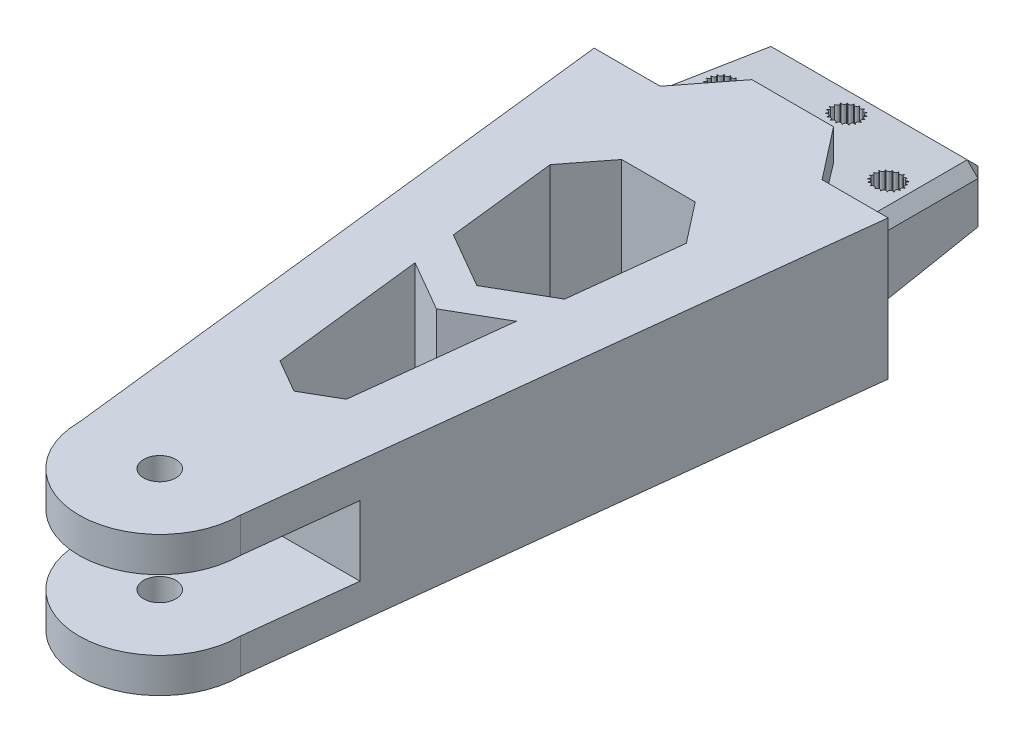
from build123d import *
from OCP.BRepFilletAPI import BRepFilletAPI_MakeChamfer

# Parameters (mm, degrees)
SKETCH2_R           = 3
SKETCH2_R_2         = 5
BOSS_EXTRUDE1_DEPTH = 26
SKETCH3_W           = 70
SKETCH3_H           = 13
CUT_EXTRUDE1_DEPTH  = 27.5
CUT_EXTRUDE2_DEPTH  = 63
CUT_EXTRUDE3_DEPTH  = 101
BOSS_EXTRUDE2_START = -9.6
SKETCH8_W           = 44.742467558
SKETCH8_H           = 16
BOSS_EXTRUDE2_DEPTH = 26
BOSS_EXTRUDE2_TAPER = 5
CUT_EXTRUDE4_REACH  = 145.455
SKETCH10_R          = 2
CHAMFER1_SIZE       = 2
CHAMFER1_SIZE2      = 2.200125735
CHAMFER1_SIZE2_2    = 2.015367123
CUT_EXTRUDE6_DEPTH  = 54
BOSS_EXTRUDE3_DEPTH = 26
SKETCH13_R          = 2
CUT_EXTRUDE7_DEPTH  = 22


with BuildPart() as part:
    # Sketch2 → Boss-Extrude1 (new body)
    with BuildSketch(Plane(origin=(0, 0, 0), x_dir=(1, 0, 0), z_dir=(0, 1, 0))):
        with BuildLine():
            ThreePointArc((15, 350), (0, 365), (-15, 350))
            Line((-15, 350), (-31.325519493, 207.151704434))
            Line((-31.325519493, 207.151704434), (-24.254451681, 200.080636622))
            Line((-24.254451681, 200.080636622), (-24.254451681, 149.919363378))
            Line((-24.254451681, 149.919363378), (-31.325519493, 142.848295566))
            Line((-31.325519493, 142.848295566), (-15, 0))
            ThreePointArc((-15, 0), (0, -15), (15, 0))
            Line((15, 0), (31.325519493, 142.848295566))
            Line((31.325519493, 142.848295566), (24.254451681, 149.919363378))
            Line((24.254451681, 149.919363378), (24.254451681, 200.080636622))
            Line((24.254451681, 200.080636622), (31.325519493, 207.151704434))
            Line((31.325519493, 207.151704434), (15, 350))
        make_face()
        with Locations(Location((0, 0, 0), (0, 0, 90))):
            Circle(SKETCH2_R, mode=Mode.SUBTRACT)
        with Locations(Location((0, 175, 0), (0, 0, 90))):
            Circle(SKETCH2_R_2, mode=Mode.SUBTRACT)
        with Locations(Location((0, 350, 0), (0, 0, 90))):
            Circle(SKETCH2_R, mode=Mode.SUBTRACT)
    extrude(amount=BOSS_EXTRUDE1_DEPTH)

    # Sketch3 → Cut-Extrude1 (cut, symmetric)
    with BuildSketch(Plane(origin=(0, 0, 0), x_dir=(0, 0, -1), z_dir=(1, 0, 0))):
        with Locations((-15, 13)):
            Rectangle(SKETCH3_W, SKETCH3_H)
    cut_extrude1 = extrude(amount=CUT_EXTRUDE1_DEPTH, both=True, mode=Mode.SUBTRACT)

    # Sketch5 → Cut-Extrude2 (cut, symmetric)
    with BuildSketch(Plane(origin=(24.254451681, 0, 0), x_dir=(0, 0, -1), z_dir=(1, 0, 0))):
        Polygon((142.848295566, 26), (149.919363378, 23.456766037), (200.080636622, 23.456766037), (207.151704434, 26), align=None)
        Polygon((207.151704434, 0), (200.080636622, 2.543233963), (149.919363378, 2.543233963), (142.848295566, 0), align=None)
    extrude(amount=CUT_EXTRUDE2_DEPTH, both=True, mode=Mode.SUBTRACT)

    # Mirror3: Cut-Extrude1 across plane
    add(cut_extrude1.mirror(Plane.XY.offset(-175)), mode=Mode.SUBTRACT)

    # Sketch7 → Cut-Extrude3 (cut)
    with BuildSketch(Plane(origin=(0, 26, 0), x_dir=(1, 0, 0), z_dir=(0, 1, 0))):
        Polygon((7.6, 117.848295566), (-7.6, 117.848295566), (-15.071233779, 108.248295566), (-27.371233779, 108.248295566), (-64.491308862, 177.382723315), (-40.66046147, 301.084223493), (-15.371233779, 412.054906588), (101.659229405, 225.690460338), (42.092569242, 95.10562793), (27.371233779, 108.248295566), (15.071233779, 108.248295566), align=None)
    extrude(amount=-CUT_EXTRUDE3_DEPTH, mode=Mode.SUBTRACT)

    # Sketch8 → Boss-Extrude2 (add)
    with BuildSketch(Plane(origin=(0, 0, -117.848295566), x_dir=(-1, 0, 0), z_dir=(0, 0, -1)).offset(BOSS_EXTRUDE2_START)):
        with Locations((0, 13)):
            Rectangle(SKETCH8_W, SKETCH8_H)
    extrude(amount=BOSS_EXTRUDE2_DEPTH, taper=BOSS_EXTRUDE2_TAPER)

    # Cut-Extrude4: from a plane face, 145.455 long prism both ways, kept between that surface and its translate by the depth
    cut_extrude4_start = Plane(origin=(15.071233779, 21, -108.248295566), z_dir=(0, 0.9961946980917455, -0.08715574274765836)) * Box(583.82, 583.82, 291.91, align=(Align.CENTER, Align.CENTER, Align.MIN), mode=Mode.PRIVATE)
    cut_extrude4_end = Plane(origin=(15.071233779, 17, -108.248295566), z_dir=(0, 0.9961946980917455, -0.08715574274765836)) * Box(583.82, 583.82, 291.91, align=(Align.CENTER, Align.CENTER, Align.MIN), mode=Mode.PRIVATE)
    # Sketch10 → Cut-Extrude4 (cut, from a surface)
    with BuildSketch(Plane(origin=(0, 26, 0), x_dir=(1, 0, 0), z_dir=(0, 1, 0)), mode=Mode.PRIVATE) as cut_extrude4_sk1:
        with BuildLine():
            ThreePointArc((-0.17288727, 130.592855639), (-0.2270932, 130.588902922), (-0.281210428, 130.583879726))
            ThreePointArc((-0.281210428, 130.583879726), (-0.576890895, 130.126386191), (-1.054676959, 130.388011399))
            ThreePointArc((-1.054676959, 130.388011399), (-1.104662418, 130.366672214), (-1.154216396, 130.344349354))
            ThreePointArc((-1.154216396, 130.344349354), (-1.285328172, 129.81563679), (-1.822176035, 129.907949541))
            ThreePointArc((-1.822176035, 129.907949541), (-1.862524322, 129.87153632), (-1.902145108, 129.834332823))
            ThreePointArc((-1.902145108, 129.834332823), (-1.854480197, 129.291695441), (-2.392214064, 129.204692216))
            ThreePointArc((-2.392214064, 129.204692216), (-2.418552816, 129.157150897), (-2.443946883, 129.10909834))
            ThreePointArc((-2.443946883, 129.10909834), (-2.222670518, 128.611339319), (-2.70301858, 128.354448267))
            ThreePointArc((-2.70301858, 128.354448267), (-2.712493584, 128.300930689), (-2.720909091, 128.247236312))
            ThreePointArc((-2.720909091, 128.247236312), (-2.35, 127.848295566), (-2.720909091, 127.44935482))
            ThreePointArc((-2.720909091, 127.44935482), (-2.712493584, 127.395660443), (-2.70301858, 127.342142865))
            ThreePointArc((-2.70301858, 127.342142865), (-2.222670518, 127.085251813), (-2.443946883, 126.587492792))
            ThreePointArc((-2.443946883, 126.587492792), (-2.418552816, 126.539440235), (-2.392214064, 126.491898916))
            ThreePointArc((-2.392214064, 126.491898916), (-1.854480197, 126.404895691), (-1.902145108, 125.862258309))
            ThreePointArc((-1.902145108, 125.862258309), (-1.862524322, 125.825054812), (-1.822176035, 125.788641591))
            ThreePointArc((-1.822176035, 125.788641591), (-1.285328172, 125.880954342), (-1.154216396, 125.352241778))
            ThreePointArc((-1.154216396, 125.352241778), (-1.104662418, 125.329918918), (-1.054676959, 125.308579733))
            ThreePointArc((-1.054676959, 125.308579733), (-0.576890895, 125.570204941), (-0.281210428, 125.112711406))
            ThreePointArc((-0.281210428, 125.112711406), (-0.2270932, 125.10768821), (-0.17288727, 125.103735493))
            ThreePointArc((-0.17288727, 125.103735493), (0.194061462, 125.506322007), (0.622269053, 125.169624025))
            ThreePointArc((0.622269053, 125.169624025), (0.67508509, 125.182444835), (0.727637438, 125.196306924))
            ThreePointArc((0.727637438, 125.196306924), (0.943984248, 125.696228248), (1.458316027, 125.516812269))
            ThreePointArc((1.458316027, 125.516812269), (1.504107435, 125.546087751), (1.549311339, 125.576262473))
            ThreePointArc((1.549311339, 125.576262473), (1.591611693, 126.119344376), (2.136331831, 126.116652905))
            ThreePointArc((2.136331831, 126.116652905), (2.170136401, 126.159210606), (2.203093317, 126.202428063))
            ThreePointArc((2.203093317, 126.202428063), (2.066763315, 126.729819192), (2.582842933, 126.904143892))
            ThreePointArc((2.582842933, 126.904143892), (2.600997415, 126.955372026), (2.618135949, 127.006948935))
            ThreePointArc((2.618135949, 127.006948935), (2.317949063, 127.461498279), (2.749462926, 127.793948363))
            ThreePointArc((2.749462926, 127.793948363), (2.75, 127.848295566), (2.749462926, 127.902642769))
            ThreePointArc((2.749462926, 127.902642769), (2.317949063, 128.235092853), (2.618135949, 128.689642197))
            ThreePointArc((2.618135949, 128.689642197), (2.600997415, 128.741219106), (2.582842933, 128.79244724))
            ThreePointArc((2.582842933, 128.79244724), (2.066763315, 128.96677194), (2.203093317, 129.494163069))
            ThreePointArc((2.203093317, 129.494163069), (2.170136401, 129.537380526), (2.136331831, 129.579938227))
            ThreePointArc((2.136331831, 129.579938227), (1.591611693, 129.577246756), (1.549311339, 130.120328659))
            ThreePointArc((1.549311339, 130.120328659), (1.504107435, 130.150503381), (1.458316027, 130.179778863))
            ThreePointArc((1.458316027, 130.179778863), (0.943984248, 130.000362884), (0.727637438, 130.500284208))
            ThreePointArc((0.727637438, 130.500284208), (0.67508509, 130.514146297), (0.622269053, 130.526967107))
            ThreePointArc((0.622269053, 130.526967107), (0.194061462, 130.190269125), (-0.17288727, 130.592855639))
        make_face()
    cut_extrude4_tool1 = extrude(cut_extrude4_sk1.sketch, amount=CUT_EXTRUDE4_REACH, both=True, mode=Mode.PRIVATE)
    add(((cut_extrude4_tool1 - cut_extrude4_start) & cut_extrude4_end).solids().sort_by_distance((0, 17.617679, -127.848296))[0], mode=Mode.SUBTRACT)
    # Sketch10 → Cut-Extrude4 (cut, from a surface)
    with BuildSketch(Plane(origin=(0, 26, 0), x_dir=(1, 0, 0), z_dir=(0, 1, 0)), mode=Mode.PRIVATE) as cut_extrude4_sk2:
        with BuildLine():
            ThreePointArc((-12.621770853, 120.193948363), (-12.621233779, 120.248295566), (-12.621770853, 120.302642769))
            ThreePointArc((-12.621770853, 120.302642769), (-13.053284716, 120.635092853), (-12.75309783, 121.089642197))
            ThreePointArc((-12.75309783, 121.089642197), (-12.770236364, 121.141219106), (-12.788390846, 121.19244724))
            ThreePointArc((-12.788390846, 121.19244724), (-13.304470464, 121.36677194), (-13.168140462, 121.894163069))
            ThreePointArc((-13.168140462, 121.894163069), (-13.201097378, 121.937380526), (-13.234901948, 121.979938227))
            ThreePointArc((-13.234901948, 121.979938227), (-13.779622086, 121.977246756), (-13.82192244, 122.520328659))
            ThreePointArc((-13.82192244, 122.520328659), (-13.867126344, 122.550503381), (-13.912917752, 122.579778863))
            ThreePointArc((-13.912917752, 122.579778863), (-14.427249531, 122.400362884), (-14.643596341, 122.900284208))
            ThreePointArc((-14.643596341, 122.900284208), (-14.696148689, 122.914146297), (-14.748964726, 122.926967107))
            ThreePointArc((-14.748964726, 122.926967107), (-15.177172317, 122.590269125), (-15.544121048, 122.992855639))
            ThreePointArc((-15.544121048, 122.992855639), (-15.598326979, 122.988902922), (-15.652444207, 122.983879726))
            ThreePointArc((-15.652444207, 122.983879726), (-15.948124674, 122.526386191), (-16.425910738, 122.788011399))
            ThreePointArc((-16.425910738, 122.788011399), (-16.475896197, 122.766672214), (-16.525450175, 122.744349354))
            ThreePointArc((-16.525450175, 122.744349354), (-16.656561951, 122.21563679), (-17.193409814, 122.307949541))
            ThreePointArc((-17.193409814, 122.307949541), (-17.233758101, 122.27153632), (-17.273378887, 122.234332823))
            ThreePointArc((-17.273378887, 122.234332823), (-17.225713976, 121.691695441), (-17.763447843, 121.604692216))
            ThreePointArc((-17.763447843, 121.604692216), (-17.789786595, 121.557150897), (-17.815180662, 121.50909834))
            ThreePointArc((-17.815180662, 121.50909834), (-17.593904297, 121.011339319), (-18.074252359, 120.754448267))
            ThreePointArc((-18.074252359, 120.754448267), (-18.083727363, 120.700930689), (-18.09214287, 120.647236312))
            ThreePointArc((-18.09214287, 120.647236312), (-17.721233779, 120.248295566), (-18.09214287, 119.84935482))
            ThreePointArc((-18.09214287, 119.84935482), (-18.083727363, 119.795660443), (-18.074252359, 119.742142865))
            ThreePointArc((-18.074252359, 119.742142865), (-17.593904297, 119.485251813), (-17.815180662, 118.987492792))
            ThreePointArc((-17.815180662, 118.987492792), (-17.789786595, 118.939440235), (-17.763447843, 118.891898916))
            ThreePointArc((-17.763447843, 118.891898916), (-17.225713976, 118.804895691), (-17.273378887, 118.262258309))
            ThreePointArc((-17.273378887, 118.262258309), (-17.233758101, 118.225054812), (-17.193409814, 118.188641591))
            ThreePointArc((-17.193409814, 118.188641591), (-16.656561951, 118.280954342), (-16.525450175, 117.752241778))
            ThreePointArc((-16.525450175, 117.752241778), (-16.475896197, 117.729918918), (-16.425910738, 117.708579733))
            ThreePointArc((-16.425910738, 117.708579733), (-15.948124674, 117.970204941), (-15.652444207, 117.512711406))
            ThreePointArc((-15.652444207, 117.512711406), (-15.598326979, 117.50768821), (-15.544121048, 117.503735493))
            ThreePointArc((-15.544121048, 117.503735493), (-15.177172317, 117.906322007), (-14.748964726, 117.569624025))
            ThreePointArc((-14.748964726, 117.569624025), (-14.696148689, 117.582444835), (-14.643596341, 117.596306924))
            ThreePointArc((-14.643596341, 117.596306924), (-14.427249531, 118.096228248), (-13.912917752, 117.916812269))
            ThreePointArc((-13.912917752, 117.916812269), (-13.867126344, 117.946087751), (-13.82192244, 117.976262473))
            ThreePointArc((-13.82192244, 117.976262473), (-13.779622086, 118.519344376), (-13.234901948, 118.516652905))
            ThreePointArc((-13.234901948, 118.516652905), (-13.201097378, 118.559210606), (-13.168140462, 118.602428063))
            ThreePointArc((-13.168140462, 118.602428063), (-13.304470464, 119.129819192), (-12.788390846, 119.304143892))
            ThreePointArc((-12.788390846, 119.304143892), (-12.770236364, 119.355372026), (-12.75309783, 119.406948935))
            ThreePointArc((-12.75309783, 119.406948935), (-13.053284716, 119.861498279), (-12.621770853, 120.193948363))
        make_face()
    cut_extrude4_tool2 = extrude(cut_extrude4_sk2.sketch, amount=CUT_EXTRUDE4_REACH, both=True, mode=Mode.PRIVATE)
    add(((cut_extrude4_tool2 - cut_extrude4_start) & cut_extrude4_end).solids().sort_by_distance((0, 17.617679, -127.848296))[0], mode=Mode.SUBTRACT)
    # Sketch10 → Cut-Extrude4 (cut, from a surface)
    with BuildSketch(Plane(origin=(0, 26, 0), x_dir=(1, 0, 0), z_dir=(0, 1, 0)), mode=Mode.PRIVATE) as cut_extrude4_sk3:
        with BuildLine():
            ThreePointArc((17.815180662, 118.987492792), (17.593904297, 119.485251813), (18.074252359, 119.742142865))
            ThreePointArc((18.074252359, 119.742142865), (18.083727363, 119.795660443), (18.09214287, 119.84935482))
            ThreePointArc((18.09214287, 119.84935482), (17.721233779, 120.248295566), (18.09214287, 120.647236312))
            ThreePointArc((18.09214287, 120.647236312), (18.083727363, 120.700930689), (18.074252359, 120.754448267))
            ThreePointArc((18.074252359, 120.754448267), (17.593904297, 121.011339319), (17.815180662, 121.50909834))
            ThreePointArc((17.815180662, 121.50909834), (17.789786595, 121.557150897), (17.763447843, 121.604692216))
            ThreePointArc((17.763447843, 121.604692216), (17.225713976, 121.691695441), (17.273378887, 122.234332823))
            ThreePointArc((17.273378887, 122.234332823), (17.233758101, 122.27153632), (17.193409814, 122.307949541))
            ThreePointArc((17.193409814, 122.307949541), (16.656561951, 122.21563679), (16.525450175, 122.744349354))
            ThreePointArc((16.525450175, 122.744349354), (16.475896197, 122.766672214), (16.425910738, 122.788011399))
            ThreePointArc((16.425910738, 122.788011399), (15.948124674, 122.526386191), (15.652444207, 122.983879726))
            ThreePointArc((15.652444207, 122.983879726), (15.598326979, 122.988902922), (15.544121048, 122.992855639))
            ThreePointArc((15.544121048, 122.992855639), (15.177172317, 122.590269125), (14.748964726, 122.926967107))
            ThreePointArc((14.748964726, 122.926967107), (14.696148689, 122.914146297), (14.643596341, 122.900284208))
            ThreePointArc((14.643596341, 122.900284208), (14.427249531, 122.400362884), (13.912917752, 122.579778863))
            ThreePointArc((13.912917752, 122.579778863), (13.867126344, 122.550503381), (13.82192244, 122.520328659))
            ThreePointArc((13.82192244, 122.520328659), (13.779622086, 121.977246756), (13.234901948, 121.979938227))
            ThreePointArc((13.234901948, 121.979938227), (13.201097378, 121.937380526), (13.168140462, 121.894163069))
            ThreePointArc((13.168140462, 121.894163069), (13.304470464, 121.36677194), (12.788390846, 121.19244724))
            ThreePointArc((12.788390846, 121.19244724), (12.770236364, 121.141219106), (12.75309783, 121.089642197))
            ThreePointArc((12.75309783, 121.089642197), (13.053284716, 120.635092853), (12.621770853, 120.302642769))
            ThreePointArc((12.621770853, 120.302642769), (12.621233779, 120.248295566), (12.621770853, 120.193948363))
            ThreePointArc((12.621770853, 120.193948363), (13.053284716, 119.861498279), (12.75309783, 119.406948935))
            ThreePointArc((12.75309783, 119.406948935), (12.770236364, 119.355372026), (12.788390846, 119.304143892))
            ThreePointArc((12.788390846, 119.304143892), (13.304470464, 119.129819192), (13.168140462, 118.602428063))
            ThreePointArc((13.168140462, 118.602428063), (13.201097378, 118.559210606), (13.234901948, 118.516652905))
            ThreePointArc((13.234901948, 118.516652905), (13.779622086, 118.519344376), (13.82192244, 117.976262473))
            ThreePointArc((13.82192244, 117.976262473), (13.867126344, 117.946087751), (13.912917752, 117.916812269))
            ThreePointArc((13.912917752, 117.916812269), (14.427249531, 118.096228248), (14.643596341, 117.596306924))
            ThreePointArc((14.643596341, 117.596306924), (14.696148689, 117.582444835), (14.748964726, 117.569624025))
            ThreePointArc((14.748964726, 117.569624025), (15.177172317, 117.906322007), (15.544121048, 117.503735493))
            ThreePointArc((15.544121048, 117.503735493), (15.598326979, 117.50768821), (15.652444207, 117.512711406))
            ThreePointArc((15.652444207, 117.512711406), (15.948124674, 117.970204941), (16.425910738, 117.708579733))
            ThreePointArc((16.425910738, 117.708579733), (16.475896197, 117.729918918), (16.525450175, 117.752241778))
            ThreePointArc((16.525450175, 117.752241778), (16.656561951, 118.280954342), (17.193409814, 118.188641591))
            ThreePointArc((17.193409814, 118.188641591), (17.233758101, 118.225054812), (17.273378887, 118.262258309))
            ThreePointArc((17.273378887, 118.262258309), (17.225713976, 118.804895691), (17.763447843, 118.891898916))
            ThreePointArc((17.763447843, 118.891898916), (17.789786595, 118.939440235), (17.815180662, 118.987492792))
        make_face()
        with Locations(Location((15.371233779, 120.248295566, 0), (0, 0, 270))):
            Circle(SKETCH10_R, mode=Mode.SUBTRACT)
    cut_extrude4_tool3 = extrude(cut_extrude4_sk3.sketch, amount=CUT_EXTRUDE4_REACH, both=True, mode=Mode.PRIVATE)
    add(((cut_extrude4_tool3 - cut_extrude4_start) & cut_extrude4_end).solids().sort_by_distance((0, 17.617679, -127.848296))[0], mode=Mode.SUBTRACT)

    # Chamfer1: one chamfer whose edges measure the first distance from different faces: ONE call of the kernel's chamfer builder (chamfer() names one face for all edges)
    chamfer1_edges_1 = [part.edges().sort_by_distance(p)[0] for p in [
        (0, 18.725294748, -134.248295566),
        (0, 7.274705252, -134.248295566),
        (20.096528527, 13, -134.248295566),
        (-20.096528527, 13, -134.248295566),
    ]]
    chamfer1_side_1 = [part.faces().sort_by_distance(p)[0] for p in [
        (0, 13, -134.248295566),
    ]]
    chamfer1_edges_2 = [part.edges().sort_by_distance(p)[0] for p in [
        (-21.233881153, 19.862647374, -121.248295566),
    ]]
    chamfer1_side_2 = [part.faces().sort_by_distance(p)[0] for p in [
        (-21.296712639, 13, -120.530128396),
    ]]
    chamfer1_edges_3 = [part.edges().sort_by_distance(p)[0] for p in [
        (21.233881153, 6.137352626, -121.248295566),
    ]]
    chamfer1_side_3 = [part.faces().sort_by_distance(p)[0] for p in [
        (21.296712639, 13, -120.530128396),
    ]]
    chamfer1_edges_4 = [part.edges().sort_by_distance(p)[0] for p in [
        (21.233881153, 19.862647374, -121.248295566),
    ]]
    chamfer1_side_4 = [part.faces().sort_by_distance(p)[0] for p in [
        (0, 19.698548957, -123.123949062),
    ]]
    chamfer1_edges_5 = [part.edges().sort_by_distance(p)[0] for p in [
        (-21.233881153, 6.137352626, -121.248295566),
    ]]
    chamfer1_side_5 = [part.faces().sort_by_distance(p)[0] for p in [
        (0, 6.299512188, -123.101787839),
    ]]
    chamfer1 = BRepFilletAPI_MakeChamfer(part.part.solid().wrapped)
    for e in chamfer1_edges_1:
        chamfer1.Add(CHAMFER1_SIZE, CHAMFER1_SIZE2, e.wrapped, chamfer1_side_1[0].wrapped)  # the first distance lies on this face
    for e in chamfer1_edges_2:
        chamfer1.Add(CHAMFER1_SIZE, CHAMFER1_SIZE2_2, e.wrapped, chamfer1_side_2[0].wrapped)  # the first distance lies on this face
    for e in chamfer1_edges_3:
        chamfer1.Add(CHAMFER1_SIZE, CHAMFER1_SIZE2_2, e.wrapped, chamfer1_side_3[0].wrapped)  # the first distance lies on this face
    for e in chamfer1_edges_4:
        chamfer1.Add(CHAMFER1_SIZE, CHAMFER1_SIZE2_2, e.wrapped, chamfer1_side_4[0].wrapped)  # the first distance lies on this face
    for e in chamfer1_edges_5:
        chamfer1.Add(CHAMFER1_SIZE, CHAMFER1_SIZE2_2, e.wrapped, chamfer1_side_5[0].wrapped)  # the first distance lies on this face
    add(Compound.cast(chamfer1.Shape()), mode=Mode.REPLACE)

    # Sketch11 → Cut-Extrude6 (cut)
    with BuildSketch(Plane(origin=(0, 26, 0), x_dir=(1, 0, 0), z_dir=(0, 1, 0))):
        Polygon((0, 25), (-6.187284656, 28.572230462), (-12.677671026, 85.363111205), (-6.85229996, 92.848295566), (6.85229996, 92.848295566), (12.677671026, 85.363111205), (6.187284656, 28.572230462), align=None)
    extrude(amount=-CUT_EXTRUDE6_DEPTH, mode=Mode.SUBTRACT)

    # Sketch12 → Boss-Extrude3 (add)
    with BuildSketch(Plane(origin=(0, 26, 0), x_dir=(1, 0, 0), z_dir=(0, 1, 0))):
        Polygon((-9.432477841, 56.967670833), (0, 51.521827212), (9.432477841, 56.967670833), (10.353205546, 65.024038249), (0, 59.04661224), (-10.353205546, 65.024038249), align=None)
    extrude(amount=-BOSS_EXTRUDE3_DEPTH)

    # Sketch13 → Cut-Extrude7 (cut)
    with BuildSketch(Plane(origin=(0, 0, 0), x_dir=(1, 0, 0), z_dir=(0, 1, 0))):
        with Locations(Location((15.371233779, 120.248295566, 0), (0, 0, 90))):
            Circle(SKETCH13_R)
        with Locations(Location((0, 127.848295566, 0), (0, 0, 90))):
            Circle(SKETCH13_R)
        with Locations(Location((-15.371233779, 120.248295566, 0), (0, 0, 90))):
            Circle(SKETCH13_R)
    extrude(amount=CUT_EXTRUDE7_DEPTH, mode=Mode.SUBTRACT)


solid = part.part
